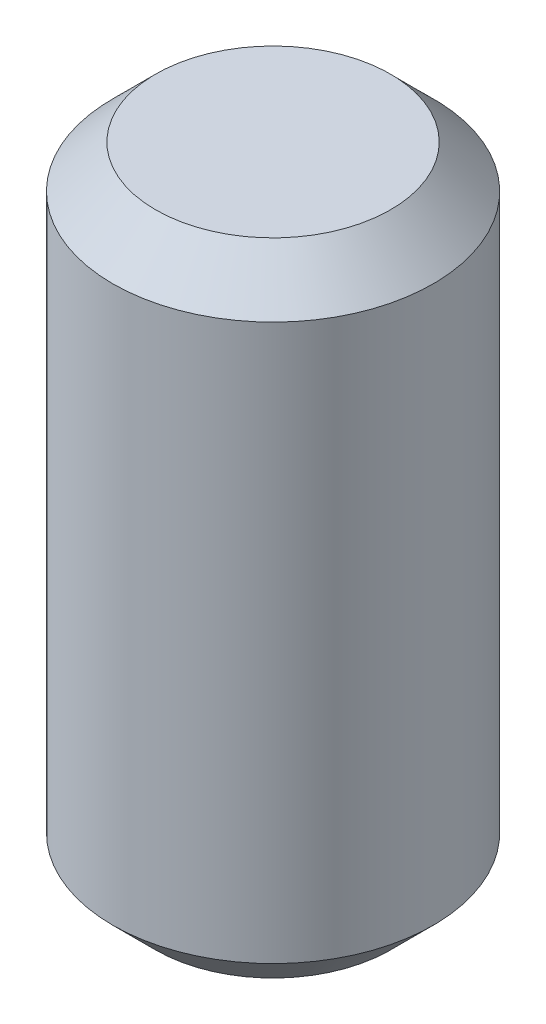
from build123d import *

# Parameters (mm, degrees)
SKETCH1_R           = 7.5
BOSS_EXTRUDE1_DEPTH = 15
CHAMFER2_SIZE       = 2


with BuildPart() as part:
    # Sketch1 → Boss-Extrude1 (new body, symmetric)
    with BuildSketch(Plane(origin=(0, 0, 0), x_dir=(1, 0, 0), z_dir=(0, 1, 0))):
        Circle(SKETCH1_R)
    extrude(amount=BOSS_EXTRUDE1_DEPTH, both=True)

    # Chamfer2
    chamfer2_edges = [part.edges().sort_by_distance(p)[0] for p in [
        (-7.5, -15, 0),
        (-7.5, 15, 0),
    ]]
    chamfer(chamfer2_edges, length=CHAMFER2_SIZE)


solid = part.part
